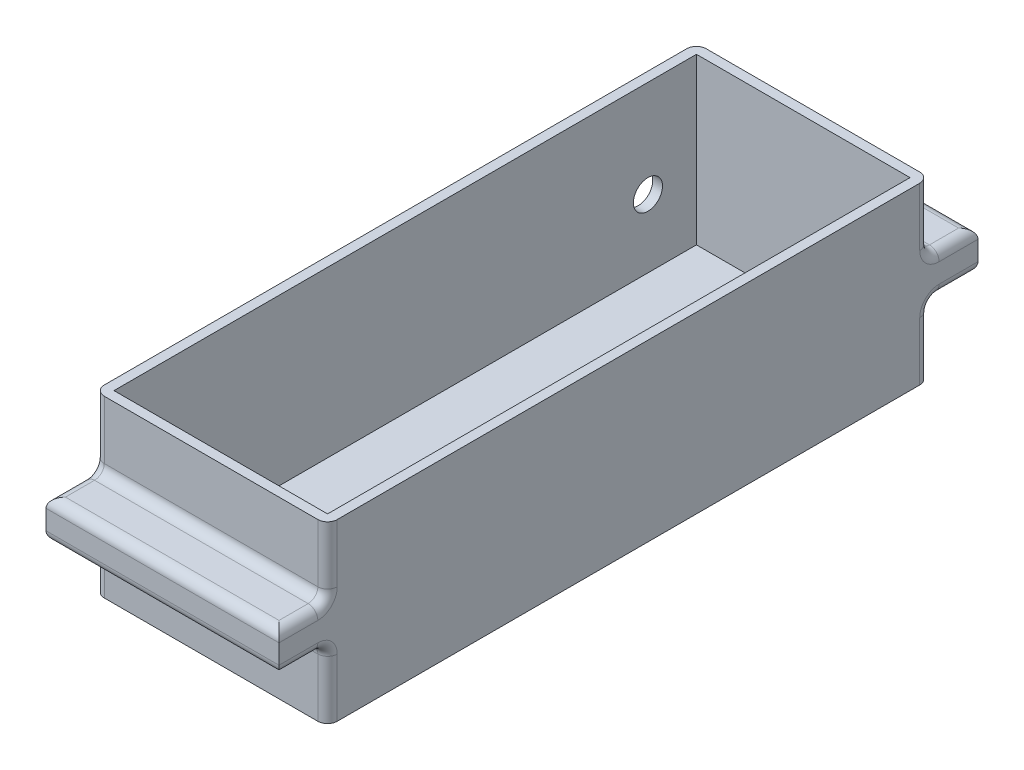
from build123d import *

# Parameters (mm, degrees)
SKETCH1_W           = 120
SKETCH1_H           = 310
BOSS_EXTRUDE4_DEPTH = 90
SHELL2_T            = -5
SKETCH2_R           = 7.499675099
CUT_EXTRUDE1_DEPTH  = 10
SKETCH3_W           = 120
SKETCH3_H           = 20
BOSS_EXTRUDE5_DEPTH = 25
SKETCH4_R           = 2.5
CUT_EXTRUDE2_DEPTH  = 20
FILLET1_R           = 5


with BuildPart() as part:
    # Sketch1 → Boss-Extrude4 (new body)
    with BuildSketch(Plane(origin=(0, 0, 0), x_dir=(1, 0, 0), z_dir=(0, 1, 0))):
        with Locations((240, 0)):
            Rectangle(SKETCH1_W, SKETCH1_H)
    extrude(amount=BOSS_EXTRUDE4_DEPTH)

    # Shell2
    shell2_openings = [part.faces().sort_by_distance(p)[0] for p in [
        (240, 90, 0),
    ]]
    offset(amount=SHELL2_T, openings=shell2_openings, kind=Kind.INTERSECTION)

    # Sketch2 → Cut-Extrude1 (cut)
    with BuildSketch(Plane.ZY.offset(-180)):
        with Locations((-125, 40)):
            Circle(SKETCH2_R)
        with Locations((125, 40)):
            Circle(SKETCH2_R)
    extrude(amount=-CUT_EXTRUDE1_DEPTH, mode=Mode.SUBTRACT)

    # Sketch3 → Boss-Extrude5 (add)
    with BuildSketch(Plane.XY.offset(180)):
        with Locations((240, 45)):
            Rectangle(SKETCH3_W, SKETCH3_H)
    boss_extrude5 = extrude(amount=-BOSS_EXTRUDE5_DEPTH)

    # Mirror1: Boss-Extrude5 across plane
    add(boss_extrude5.mirror(Plane.XY))

    # Sketch4 → Cut-Extrude2 (cut)
    with BuildSketch(Plane(origin=(180, 0, 0), x_dir=(0, 0, -1), z_dir=(1, 0, 0))):
        with Locations((-170, 45)):
            Circle(SKETCH4_R)
        with Locations((170, 45)):
            Circle(SKETCH4_R)
    extrude(amount=CUT_EXTRUDE2_DEPTH, mode=Mode.SUBTRACT)

    # Fillet1
    fillet1_edges = [part.edges().sort_by_distance(p)[0] for p in [
        (300, 17.5, 155),
        (180, 17.5, 155),
        (240, 55, 155),
        (240, 35, 155),
        (180, 55, 167.5),
        (180, 35, 167.5),
        (240, 55, 180),
        (240, 35, 180),
        (300, 55, 167.5),
        (300, 35, 167.5),
        (180, 17.5, -155),
        (300, 17.5, -155),
        (240, 35, -155),
        (240, 55, -155),
        (180, 35, -167.5),
        (240, 35, -180),
        (180, 55, -167.5),
        (300, 35, -167.5),
        (300, 55, -167.5),
        (240, 55, -180),
        (180, 72.5, -155),
        (300, 72.5, -155),
        (300, 72.5, 155),
        (180, 72.5, 155),
    ]]
    fillet(fillet1_edges, radius=FILLET1_R)


solid = part.part
